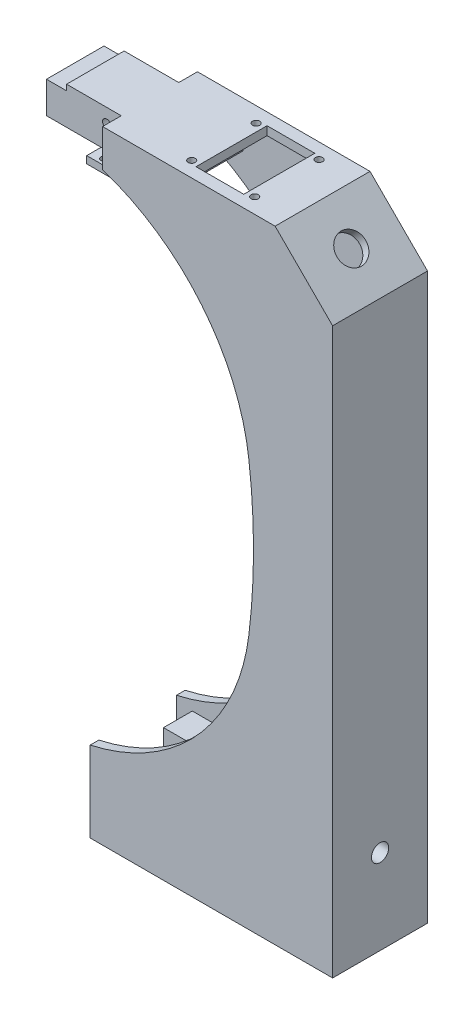
from build123d import *

# Parameters (mm, degrees)
EXTRUDE_6_DEPTH      = 33
CUT_EXTRUDE_START    = 3
CUT_EXTRUDE_2_DEPTH  = 27
EXTRUDE_START        = 6.5
SKETCH_7_W           = 26
SKETCH_7_H           = 13
EXTRUDE_7_DEPTH      = 20
EXTRUDE_START_2      = 1.5
SKETCH_11_W          = 13
SKETCH_11_H          = 2.5
EXTRUDE_15_DEPTH     = 30
CUT_EXTRUDE_START_2  = 180
SKETCH_12_R          = 1
CUT_EXTRUDE_3_DEPTH  = 10
SKETCH_13_R          = 1.5
CUT_EXTRUDE_4_DEPTH  = 30
SKETCH_14_W          = 7
SKETCH_14_H          = 2
CUT_EXTRUDE_5_DEPTH  = 30
EXTRUDE_START_3      = 11.5
SKETCH_15_W          = 67.299618531
SKETCH_15_H          = 10
EXTRUDE_16_DEPTH     = 10
SKETCH_16_W          = 8.5
SKETCH_16_H          = 10
CUT_EXTRUDE_6_DEPTH  = 79
CUT_EXTRUDE_START_3  = 16.5
SKETCH_17_R          = 3
CUT_EXTRUDE_7_DEPTH  = 75
CUT_EXTRUDE_START_4  = 13
SKETCH_18_R          = 1.5
CUT_EXTRUDE_9_DEPTH  = 5
SKETCH_20_R          = 1.25
SKETCH_20_W          = 16.6
SKETCH_20_H          = 24.7
CUT_EXTRUDE_10_DEPTH = 5
SKETCH_21_R          = 5
CUT_EXTRUDE_11_DEPTH = 5


with BuildPart() as part:
    # Эскиз1 → Бобышка-Вытянуть6 (new body)
    with BuildSketch(Plane.XY):
        with BuildLine():
            Line((4.299618531, 175.402841826), (4.299618531, 188.402841826))
            Line((4.299618531, 188.402841826), (64.299618531, 188.402841826))
            Line((64.299618531, 188.402841826), (84.299618531, 168.402841826))
            Line((84.299618531, 168.402841826), (84.299618531, 0))
            Line((84.299618531, 0), (84.299618531, -28))
            Line((84.299618531, -28), (0, -28))
            Line((0, -28), (0, 0))
            ThreePointArc((0, 0), (37.229295141, 21.561020186), (55.173142182, 60.662380285))
            ThreePointArc((55.173142182, 60.662380285), (56.797307883, 87.162380285), (55.173142182, 113.662380285))
            ThreePointArc((55.173142182, 113.662380285), (38.726552267, 151.940422917), (4.299618531, 175.402841826))
        make_face()
    extrude(amount=EXTRUDE_6_DEPTH)

    # Эскиз5 → Вырез-Вытянуть2 (cut)
    with BuildSketch(Plane.XY.offset(CUT_EXTRUDE_START)):
        Polygon((-18.700381469, -25), (81.299618531, -25), (81.299618531, -3.5), (14, -3.5), (14, 6.5), (81.299618531, 6.5), (81.299618531, 167.160201139), (63.056977844, 185.402841826), (23.056977844, 185.402841826), (23.056977844, 175.402841826), (4.299618531, 175.402841826), (6.299618531, 167.160201139), (-18.700381469, 167.160201139), align=None)
    extrude(amount=CUT_EXTRUDE_2_DEPTH, mode=Mode.SUBTRACT)

    # Эскиз7 → Бобышка-Вытянуть7 (add)
    with BuildSketch(Plane.XY.offset(EXTRUDE_START)):
        with Locations((-8.700381469, 181.902841826)):
            Rectangle(SKETCH_7_W, SKETCH_7_H)
    extrude(amount=EXTRUDE_7_DEPTH)

    # Эскиз11 → Бобышка-Вытянуть15 (add)
    with BuildSketch(Plane.XY.offset(EXTRUDE_START_2)):
        with Locations((3.799618531, 174.152841826)):
            Rectangle(SKETCH_11_W, SKETCH_11_H)
    extrude(amount=EXTRUDE_15_DEPTH)

    # Эскиз12 → Вырез-Вытянуть3 (cut)
    with BuildSketch(Plane(origin=(0, 0, 0), x_dir=(1, 0, 0), z_dir=(0, 1, 0)).offset(CUT_EXTRUDE_START_2)):
        with Locations((1.142696527, -3.5)):
            Circle(SKETCH_12_R)
        with Locations((1.142696527, -29.5)):
            Circle(SKETCH_12_R)
    extrude(amount=-CUT_EXTRUDE_3_DEPTH, mode=Mode.SUBTRACT)

    # Эскиз13 → Вырез-Вытянуть4 (cut)
    with BuildSketch(Plane.XY):
        with Locations((-0.700381469, 183.402841826)):
            Circle(SKETCH_13_R)
    extrude(amount=CUT_EXTRUDE_4_DEPTH, mode=Mode.SUBTRACT)

    # Эскиз14 → Вырез-Вытянуть5 (cut)
    with BuildSketch(Plane.XY):
        with Locations((-18.200381469, 187.402841826)):
            Rectangle(SKETCH_14_W, SKETCH_14_H)
    extrude(amount=CUT_EXTRUDE_5_DEPTH, mode=Mode.SUBTRACT)

    # Эскиз15 → Бобышка-Вытянуть16 (add)
    with BuildSketch(Plane.XY.offset(EXTRUDE_START_3)):
        with Locations((47.649809266, 1.5)):
            Rectangle(SKETCH_15_W, SKETCH_15_H)
    extrude(amount=EXTRUDE_16_DEPTH)

    # Эскиз16 → Вырез-Вытянуть6 (cut)
    with BuildSketch(Plane(origin=(0, 0, 0), x_dir=(0, 0, -1), z_dir=(1, 0, 0))):
        with Locations((-7.25, 1.5)):
            Rectangle(SKETCH_16_W, SKETCH_16_H)
        with Locations((-25.75, 1.5)):
            Rectangle(SKETCH_16_W, SKETCH_16_H)
    extrude(amount=CUT_EXTRUDE_6_DEPTH, mode=Mode.SUBTRACT)

    # Эскиз17 → Вырез-Вытянуть7 (cut)
    with BuildSketch(Plane(origin=(0, 0, 0), x_dir=(0, 0, -1), z_dir=(1, 0, 0)).offset(CUT_EXTRUDE_START_3)):
        with Locations((-16.5, 1.5)):
            Circle(SKETCH_17_R)
    extrude(amount=CUT_EXTRUDE_7_DEPTH, mode=Mode.SUBTRACT)

    # Эскиз18 → Вырез-Вытянуть9 (cut)
    with BuildSketch(Plane(origin=(0, 0, 0), x_dir=(0, 0, -1), z_dir=(1, 0, 0)).offset(CUT_EXTRUDE_START_4)):
        with Locations((-16.5, 1.5)):
            Circle(SKETCH_18_R)
    extrude(amount=CUT_EXTRUDE_9_DEPTH, mode=Mode.SUBTRACT)

    # Эскиз20 → Вырез-Вытянуть10 (cut)
    with BuildSketch(Plane(origin=(0, 188.402841826, 0), x_dir=(1, 0, 0), z_dir=(0, 1, 0))):
        with Locations((51.9, -5.3)):
            Circle(SKETCH_20_R)
        with Locations((51.9, -27.7)):
            Circle(SKETCH_20_R)
        with Locations((30, -5.3)):
            Circle(SKETCH_20_R)
        with Locations((30, -27.7)):
            Circle(SKETCH_20_R)
        with Locations((40.95, -16.5)):
            Rectangle(SKETCH_20_W, SKETCH_20_H)
    extrude(amount=-CUT_EXTRUDE_10_DEPTH, mode=Mode.SUBTRACT)

    # Эскиз21 → Вырез-Вытянуть11 (cut)
    with BuildSketch(Plane(origin=(126.351230179, 126.351230179, 0), x_dir=(0, 0, -1), z_dir=(0.707106781, 0.707106781, 0))):
        with Locations((-16.5, 73.612095136)):
            Circle(SKETCH_21_R)
    extrude(amount=-CUT_EXTRUDE_11_DEPTH, mode=Mode.SUBTRACT)


solid = part.part
